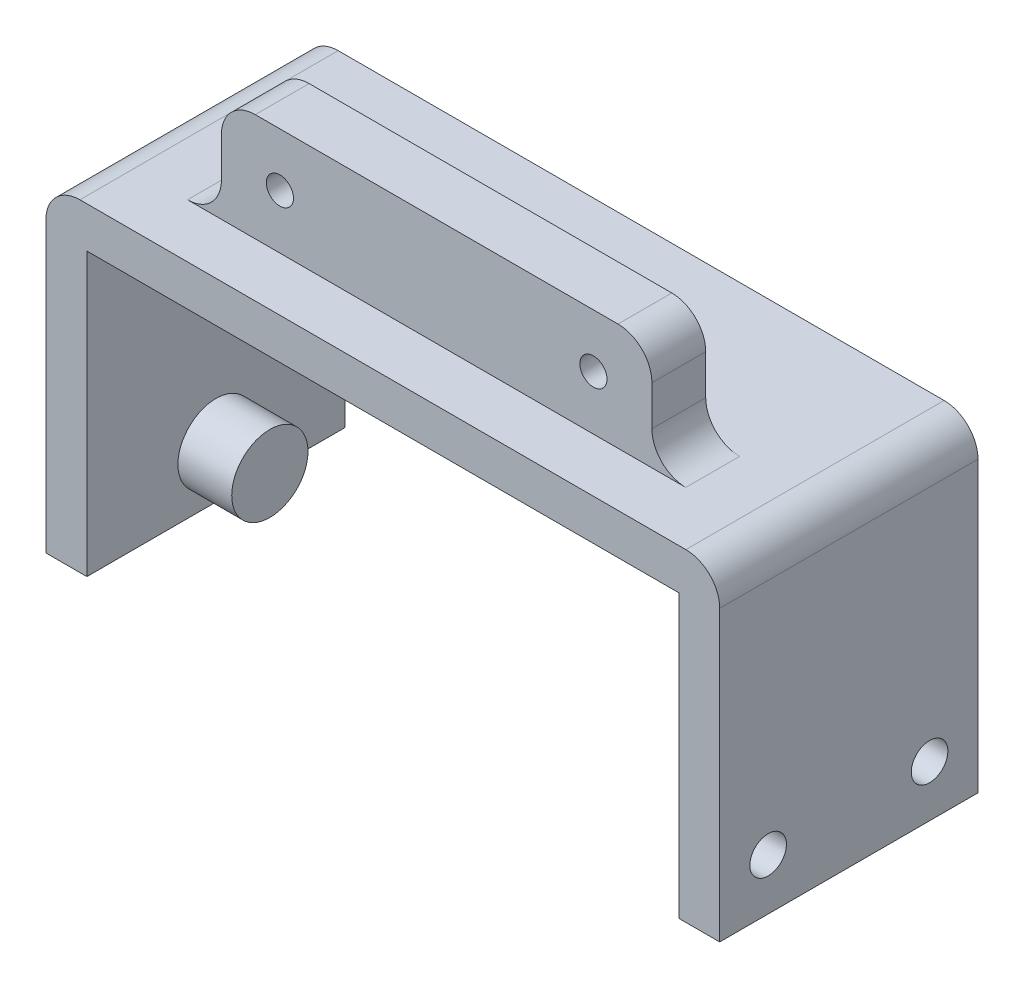
from build123d import *

# Parameters (mm, degrees)
SKETCH2_W           = 30.48
SKETCH2_H           = 38.1
SKETCH2_R           = 2.159
BOSS_EXTRUDE1_DEPTH = 4.826
SKETCH3_W           = 30.48
SKETCH3_H           = 4.826
BOSS_EXTRUDE2_DEPTH = 74.676
SKETCH4_W           = 4.826
SKETCH4_H           = 30.48
BOSS_EXTRUDE4_DEPTH = 33.274
SKETCH5_W           = 50.8
SKETCH5_H           = 6.35
BOSS_EXTRUDE5_DEPTH = 12.7
CUT_EXTRUDE1_REACH  = 14.7
SKETCH6_R           = 1.6
FILLET2_R           = 4
SKETCH7_R           = 4.5
BOSS_EXTRUDE6_DEPTH = 6.35


with BuildPart() as part:
    # Sketch2 → Boss-Extrude1 (new body)
    with BuildSketch(Plane(origin=(0, 0, 0), x_dir=(0, 0, -1), z_dir=(1, 0, 0))):
        with Locations((15.24, 19.05)):
            Rectangle(SKETCH2_W, SKETCH2_H)
        with Locations((5.715, 6.05)):
            Circle(SKETCH2_R, mode=Mode.SUBTRACT)
        with Locations((24.765, 6.05)):
            Circle(SKETCH2_R, mode=Mode.SUBTRACT)
    extrude(amount=BOSS_EXTRUDE1_DEPTH)

    # Sketch3 → Boss-Extrude2 (add)
    with BuildSketch(Plane.ZY):
        with Locations((-15.24, 35.687)):
            Rectangle(SKETCH3_W, SKETCH3_H)
    extrude(amount=BOSS_EXTRUDE2_DEPTH)

    # Sketch4 → Boss-Extrude4 (add)
    with BuildSketch(Plane.XZ.offset(-33.274)):
        with Locations((-72.263, -15.24)):
            Rectangle(SKETCH4_W, SKETCH4_H)
    extrude(amount=BOSS_EXTRUDE4_DEPTH)

    # Sketch5 → Boss-Extrude5 (add)
    with BuildSketch(Plane(origin=(0, 38.1, 0), x_dir=(1, 0, 0), z_dir=(0, 1, 0))):
        with Locations((-34.925, 9.525)):
            Rectangle(SKETCH5_W, SKETCH5_H)
    extrude(amount=BOSS_EXTRUDE5_DEPTH)

    # Sketch6 → Cut-Extrude1 (cut, up to next)
    with BuildSketch(Plane(origin=(0, 0, -12.7), x_dir=(-1, 0, 0), z_dir=(0, 0, -1)), mode=Mode.PRIVATE) as cut_extrude1_sk1:
        with Locations((16.425, 44.5)):
            Circle(SKETCH6_R)
    cut_extrude1_tool1 = extrude(cut_extrude1_sk1.sketch, amount=-CUT_EXTRUDE1_REACH, mode=Mode.PRIVATE) & part.part
    add(cut_extrude1_tool1.solids().sort_by_distance((-16.425, 44.5, -12.7))[0], mode=Mode.SUBTRACT)
    # Sketch6 → Cut-Extrude1 (cut, up to next)
    with BuildSketch(Plane(origin=(0, 0, -12.7), x_dir=(-1, 0, 0), z_dir=(0, 0, -1)), mode=Mode.PRIVATE) as cut_extrude1_sk2:
        with Locations((53.425, 44.5)):
            Circle(SKETCH6_R)
    cut_extrude1_tool2 = extrude(cut_extrude1_sk2.sketch, amount=-CUT_EXTRUDE1_REACH, mode=Mode.PRIVATE) & part.part
    add(cut_extrude1_tool2.solids().sort_by_distance((-53.425, 44.5, -12.7))[0], mode=Mode.SUBTRACT)

    # Fillet2
    fillet2_edges = [part.edges().sort_by_distance(p)[0] for p in [
        (4.826, 38.1, -15.24),
        (-74.676, 38.1, -15.24),
        (-60.325, 38.1, -9.525),
        (-9.525, 38.1, -9.525),
        (-60.325, 50.8, -9.525),
        (-9.525, 50.8, -9.525),
    ]]
    fillet(fillet2_edges, radius=FILLET2_R)

    # Sketch7 → Boss-Extrude6 (add)
    with BuildSketch(Plane(origin=(-69.85, 0, 0), x_dir=(0, 0, -1), z_dir=(1, 0, 0))):
        with Locations((15.24, 6.096)):
            Circle(SKETCH7_R)
    extrude(amount=BOSS_EXTRUDE6_DEPTH)


solid = part.part
